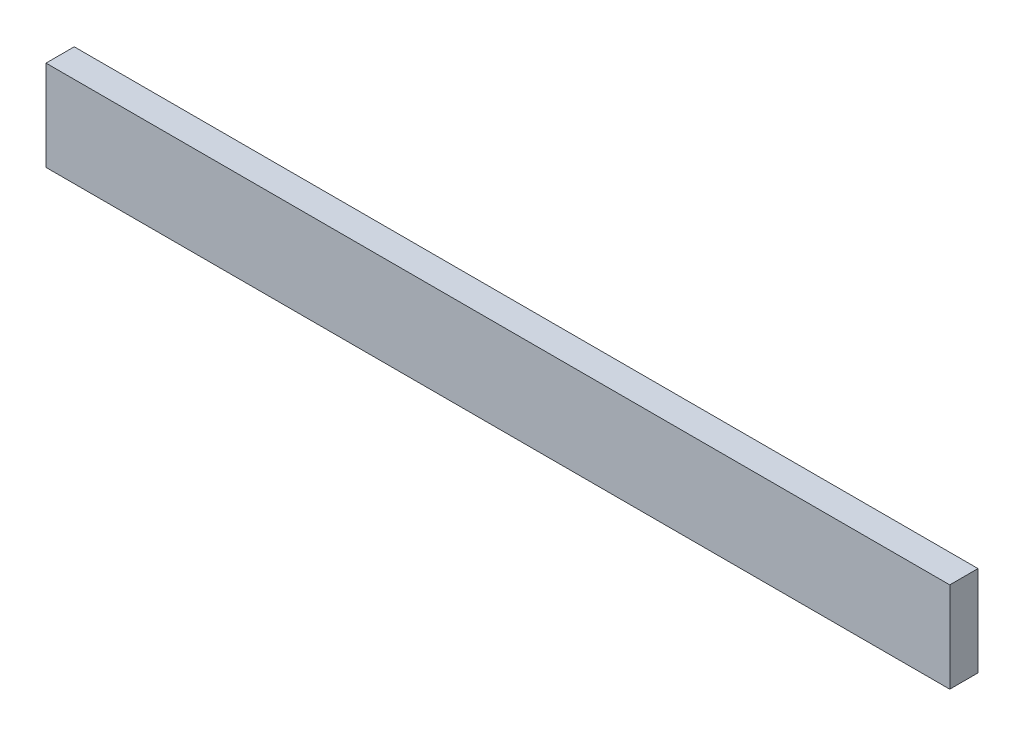
from build123d import *

# Parameters (mm, degrees)
SKETCH1_W           = 800
SKETCH1_H           = 80
BOSS_EXTRUDE1_DEPTH = 25


with BuildPart() as part:
    # Sketch1 → Boss-Extrude1 (new body)
    with BuildSketch(Plane.XY):
        with Locations((400, 40)):
            Rectangle(SKETCH1_W, SKETCH1_H)
    extrude(amount=BOSS_EXTRUDE1_DEPTH)


solid = part.part
